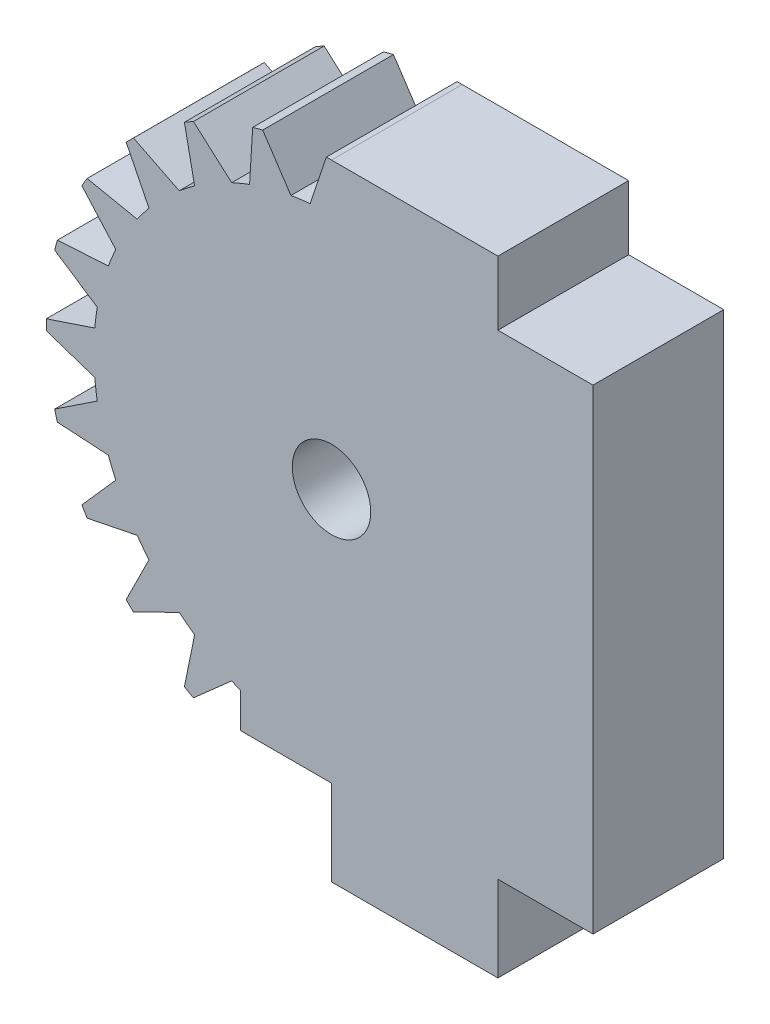
from build123d import *

# Parameters (mm, degrees)
SKETCH1_R           = 10
BOSS_EXTRUDE1_DEPTH = 5.5
BOSS_EXTRUDE2_DEPTH = 5.5
CIRPATTERN1_COUNT   = 24
SKETCH3_R           = 12.65
SKETCH3_R_2         = 12
CUT_EXTRUDE1_DEPTH  = 6
CUT_EXTRUDE2_DEPTH  = 6
SKETCH5_R           = 1.65
CUT_EXTRUDE3_DEPTH  = 6
BOSS_EXTRUDE3_DEPTH = 5.5


with BuildPart() as part:
    # Sketch1 → Boss-Extrude1 (new body)
    with BuildSketch(Plane.XY):
        Circle(SKETCH1_R)
    extrude(amount=BOSS_EXTRUDE1_DEPTH)

    # Sketch2 → Boss-Extrude2 (add)
    with BuildSketch(Plane.XY):
        with BuildLine():
            Line((0, 12.65), (-0.9, 9.959417654))
            ThreePointArc((-0.9, 9.959417654), (0, 10), (0.9, 9.959417654))
            Line((0.9, 9.959417654), (0, 12.65))
        make_face()
    boss_extrude2 = extrude(amount=BOSS_EXTRUDE2_DEPTH)

    # CirPattern1: Boss-Extrude2 ×24 about axis
    cirpattern1_axis = Axis((0, 0, 0), (0, 0, 1))
    for i in range(1, CIRPATTERN1_COUNT):
        add(boss_extrude2.rotate(cirpattern1_axis, i * 360 / CIRPATTERN1_COUNT))

    # Sketch3 → Cut-Extrude1 (cut)
    with BuildSketch(Plane.XY):
        Circle(SKETCH3_R)
        Circle(SKETCH3_R_2, mode=Mode.SUBTRACT)
    extrude(amount=CUT_EXTRUDE1_DEPTH, mode=Mode.SUBTRACT)

    # Sketch4 → Cut-Extrude2 (cut)
    with BuildSketch(Plane.XY):
        with BuildLine():
            Line((0, 0), (0, 12))
            ThreePointArc((0, 12), (11.769423365, -2.341083864), (-4.592201188, -11.08655439))
            Line((-4.592201188, -11.08655439), (-3.826834324, -9.238795325))
            Line((-3.826834324, -9.238795325), (0, 0))
        make_face()
    extrude(amount=CUT_EXTRUDE2_DEPTH, mode=Mode.SUBTRACT)

    # Sketch5 → Cut-Extrude3 (cut)
    with BuildSketch(Plane.XY):
        Circle(SKETCH5_R)
    extrude(amount=CUT_EXTRUDE3_DEPTH, mode=Mode.SUBTRACT)

    # Sketch6 → Boss-Extrude3 (add)
    with BuildSketch(Plane.XY):
        with BuildLine():
            Line((0, 1.65), (0, 12))
            Line((0, 12), (7, 12))
            Line((7, 12), (7, 9.3))
            Line((7, 9.3), (11, 9.3))
            Line((11, 9.3), (11, -10.7))
            Line((11, -10.7), (7, -10.7))
            Line((7, -10.7), (7, -14.3))
            Line((7, -14.3), (0, -14.3))
            Line((0, -14.3), (0, -10.7))
            Line((0, -10.7), (-3.826834324, -10.7))
            Line((-3.826834324, -10.7), (-3.826834324, -9.238795325))
            Line((-3.826834324, -9.238795325), (-0.631427663, -1.524401229))
            ThreePointArc((-0.631427663, -1.524401229), (1.618295713, -0.321899031), (0, 1.65))
        make_face()
    extrude(amount=BOSS_EXTRUDE3_DEPTH)


solid = part.part
